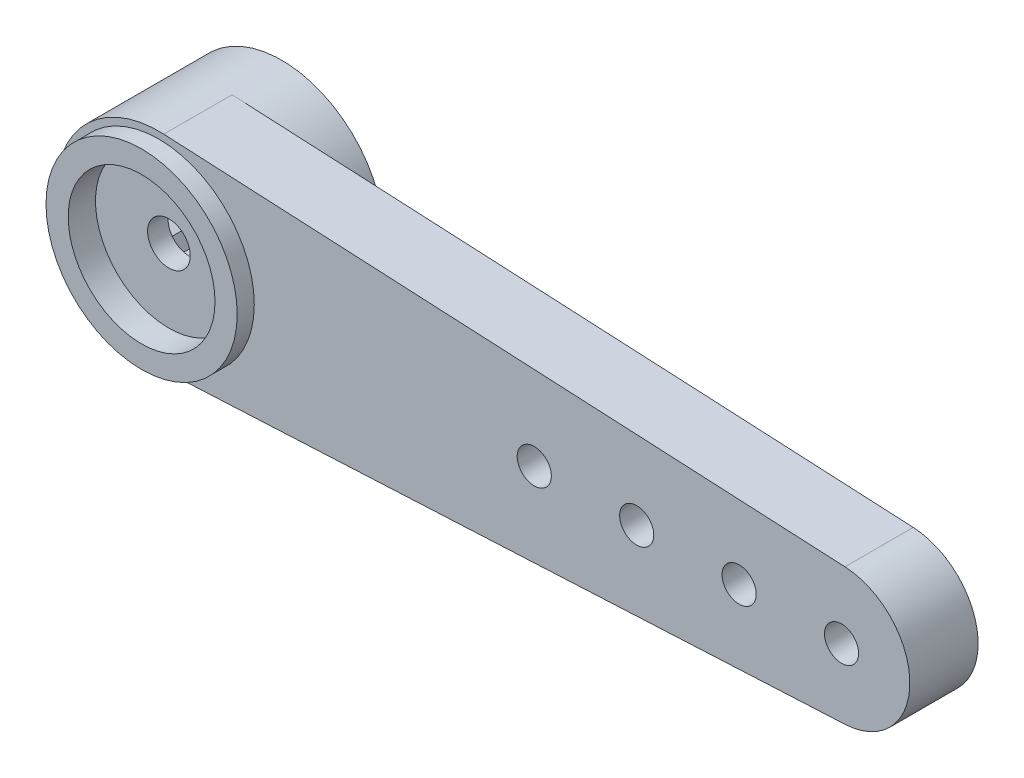
from build123d import *

# Parameters (mm, degrees)
SKETCH2_R           = 3
SKETCH2_R_2         = 2.8
BOSS_EXTRUDE1_DEPTH = 3.6
SKETCH2_3_R         = 2.8
SKETCH2_3_R_2       = 2.15
BOSS_EXTRUDE2_DEPTH = 4.1
BOSS_EXTRUDE3_START = 2.7
SKETCH2_4_R         = 2.15
SKETCH2_4_R_2       = 0.625
BOSS_EXTRUDE3_DEPTH = 0.6
SKETCH2_5_R         = 2.15
BOSS_EXTRUDE4_DEPTH = 2.7
BOSS_EXTRUDE5_START = 3.6
SKETCH2_6_R         = 0.5
BOSS_EXTRUDE5_DEPTH = 2


with BuildPart() as part:
    # Sketch2 → Boss-Extrude1 (new body)
    with BuildSketch(Plane.XY):
        Circle(SKETCH2_R)
        Circle(SKETCH2_R_2, mode=Mode.SUBTRACT)
    extrude(amount=BOSS_EXTRUDE1_DEPTH)

    # Sketch2_3 → Boss-Extrude2 (add)
    with BuildSketch(Plane.XY):
        Circle(SKETCH2_3_R)
        Circle(SKETCH2_3_R_2, mode=Mode.SUBTRACT)
    extrude(amount=BOSS_EXTRUDE2_DEPTH)

    # Sketch2_4 → Boss-Extrude3 (add)
    with BuildSketch(Plane.XY.offset(BOSS_EXTRUDE3_START)):
        Circle(SKETCH2_4_R)
        Circle(SKETCH2_4_R_2, mode=Mode.SUBTRACT)
    extrude(amount=BOSS_EXTRUDE3_DEPTH)

    # Sketch2_5 → Boss-Extrude4 (add)
    with BuildSketch(Plane.XY):
        Circle(SKETCH2_5_R)
        Polygon((-0.374241043, 1.760665681), (0, 2), (0.374241043, 1.760665681), (0.813473286, 1.827090915), (1.058013454, 1.45623059), (1.486289651, 1.338261213), (1.558845727, 0.9), (1.902113033, 0.618033989), (1.790139412, 0.188151234), (1.989043791, -0.209056927), (1.711901729, -0.55623059), (1.732050808, -1), (1.337660686, -1.204435091), (1.175570505, -1.618033989), (0.732125958, -1.644381824), (0.415823382, -1.956295201), (0, -1.8), (-0.415823382, -1.956295201), (-0.732125958, -1.644381824), (-1.175570505, -1.618033989), (-1.337660686, -1.204435091), (-1.732050808, -1), (-1.711901729, -0.55623059), (-1.989043791, -0.209056927), (-1.790139412, 0.188151234), (-1.902113033, 0.618033989), (-1.558845727, 0.9), (-1.486289651, 1.338261213), (-1.058013454, 1.45623059), (-0.813473286, 1.827090915), align=None, mode=Mode.SUBTRACT)
    extrude(amount=BOSS_EXTRUDE4_DEPTH)

    # Sketch2_6 → Boss-Extrude5 (add)
    with BuildSketch(Plane.XY.offset(BOSS_EXTRUDE5_START)):
        with BuildLine():
            Line((20.1, 1.997498436), (0.15, 2.996247653))
            ThreePointArc((0.15, 2.996247653), (3, 0), (0.15, -2.996247653))
            Line((0.15, -2.996247653), (20.1, -1.997498436))
            ThreePointArc((20.1, -1.997498436), (22, 0), (20.1, 1.997498436))
        make_face()
        with Locations((11, 0)):
            Circle(SKETCH2_6_R, mode=Mode.SUBTRACT)
        with Locations((14, 0)):
            Circle(SKETCH2_6_R, mode=Mode.SUBTRACT)
        with Locations((17, 0)):
            Circle(SKETCH2_6_R, mode=Mode.SUBTRACT)
        with Locations((20, 0)):
            Circle(SKETCH2_6_R, mode=Mode.SUBTRACT)
    extrude(amount=-BOSS_EXTRUDE5_DEPTH)


solid = part.part
